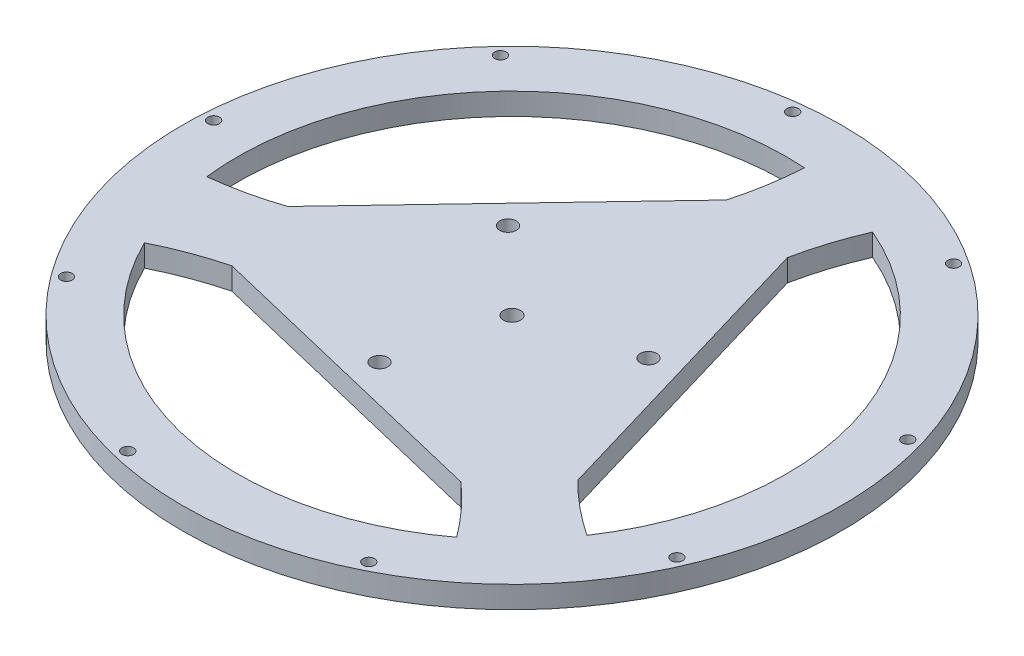
from build123d import *

# Parameters (mm, degrees)
SKETCH_3_R           = 60
SKETCH_3_R_2         = 1.052935028
SKETCH_3_R_3         = 1.5
EXTRUDE_4_DEPTH      = 4
CUT_EXTRUDE_15_DEPTH = 4
SKETCH_3_22_R        = 1.55
CUT_EXTRUDE_23_DEPTH = 10
SKETCH_3_23_R        = 1.052935028
CUT_EXTRUDE_24_DEPTH = 10


with BuildPart() as part:
    # 草图3 → 凸台-拉伸4 (new body)
    with BuildSketch(Plane(origin=(0, 0, 0), x_dir=(1, 0, 0), z_dir=(0, 1, 0))):
        Circle(SKETCH_3_R)
        with Locations((-46.641583195, -34.475537952)):
            Circle(SKETCH_3_R_2, mode=Mode.SUBTRACT)
        with Locations((-13.569076992, -56.390426045)):
            Circle(SKETCH_3_R_2, mode=Mode.SUBTRACT)
        with BuildLine():
            ThreePointArc((-44.889569885, -22.021047103), (-39.209954392, -19.560908928), (-33.307112163, -17.698983687))
            Line((-33.307112163, -17.698983687), (21.609631998, -30.913452559))
            ThreePointArc((21.609631998, -30.913452559), (26.019303967, -35.256850436), (29.958048994, -40.031428909))
            ThreePointArc((29.958048994, -40.031428909), (-11.697480165, -48.612436246), (-44.889569885, -22.021047103))
        make_face(mode=Mode.SUBTRACT)
        with Locations((-4.678992066, -19.444974498)):
            Circle(SKETCH_3_R_3, mode=Mode.SUBTRACT)
        with Locations((25.852551139, -51.919607083)):
            Circle(SKETCH_3_R_2, mode=Mode.SUBTRACT)
        with Locations((53.177483273, -23.155026944)):
            Circle(SKETCH_3_R_2, mode=Mode.SUBTRACT)
        with Locations((-14.500345858, 13.774613243)):
            Circle(SKETCH_3_R_3, mode=Mode.SUBTRACT)
        with BuildLine():
            ThreePointArc((15.967019236, 34.171216556), (17.523676152, 40.161803442), (19.689209887, 45.960145931))
            ThreePointArc((19.689209887, 45.960145931), (47.948344812, 14.175903139), (41.515571152, -27.864984334))
            ThreePointArc((41.515571152, -27.864984334), (36.545221249, -24.176362121), (31.981325576, -19.995313417))
            Line((31.981325576, -19.995313417), (15.967019236, 34.171216556))
        make_face(mode=Mode.SUBTRACT)
        with Locations((55.620079982, 16.444047642)):
            Circle(SKETCH_3_R_2, mode=Mode.SUBTRACT)
        with Locations((32.037423118, 48.34876958)):
            Circle(SKETCH_3_R_2, mode=Mode.SUBTRACT)
        with Locations((-42.05100299, 39.946378404)):
            Circle(SKETCH_3_R_2, mode=Mode.SUBTRACT)
        with Locations((-6.535900078, 57.630564895)):
            Circle(SKETCH_3_R_2, mode=Mode.SUBTRACT)
        with Locations((19.179337925, 5.670361256)):
            Circle(SKETCH_3_R_3, mode=Mode.SUBTRACT)
    extrude(amount=EXTRUDE_4_DEPTH)

    # 草图3<17> → 切除-拉伸15 (cut)
    with BuildSketch(Plane(origin=(0, 0, 0), x_dir=(1, 0, 0), z_dir=(0, 1, 0))):
        with BuildLine():
            Line((1.325786588, 37.694297104), (-37.576651234, -3.257763997))
            ThreePointArc((-37.576651234, -3.257763997), (-43.542980118, -4.904953006), (-49.647258882, -5.928717023))
            ThreePointArc((-49.647258882, -5.928717023), (-36.250864646, 34.436533107), (3.373998733, 49.886031437))
            ThreePointArc((3.373998733, 49.886031437), (2.664733143, 43.737271049), (1.325786588, 37.694297104))
        make_face()
    extrude(amount=CUT_EXTRUDE_15_DEPTH, mode=Mode.SUBTRACT)

    # 草图3<22> → 切除-拉伸23 (cut)
    with BuildSketch(Plane(origin=(0, 0, 0), x_dir=(1, 0, 0), z_dir=(0, 1, 0))):
        Circle(SKETCH_3_22_R)
    extrude(amount=CUT_EXTRUDE_23_DEPTH, mode=Mode.SUBTRACT)

    # 草图3<23> → 切除-拉伸24 (cut)
    with BuildSketch(Plane(origin=(0, 0, 0), x_dir=(1, 0, 0), z_dir=(0, 1, 0))):
        with Locations((-57.889974257, 3.570837502)):
            Circle(SKETCH_3_23_R)
    extrude(amount=CUT_EXTRUDE_24_DEPTH, mode=Mode.SUBTRACT)


solid = part.part
